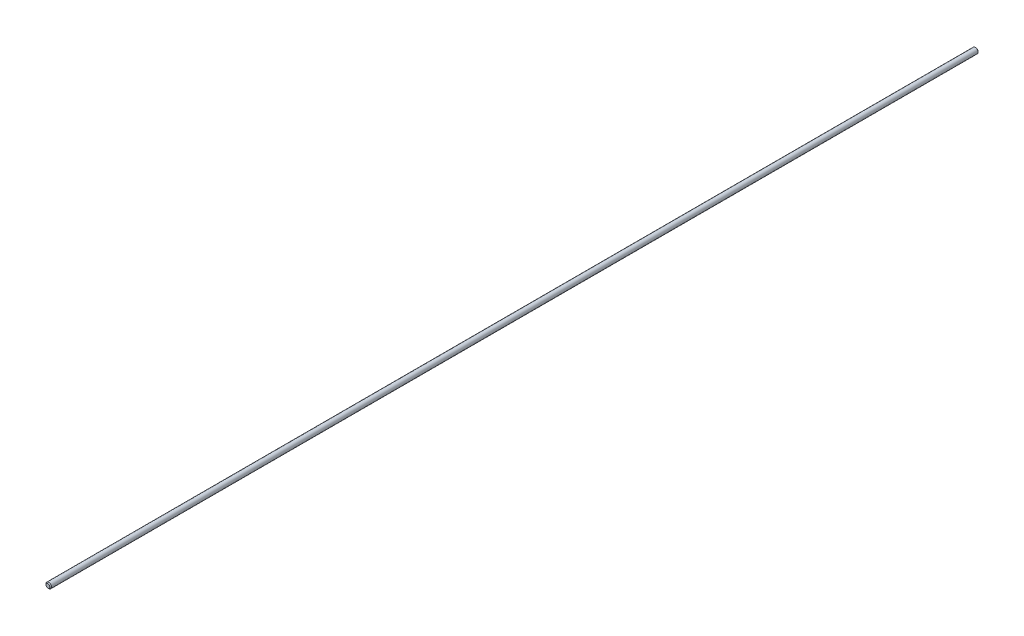
from build123d import *

# Parameters (mm, degrees)
SKETCH2_W     = 534.6954
SKETCH2_H     = 1.5875
CHAMFER1_SIZE = 0.47625


with BuildPart() as part:
    # Sketch2 → Revolve1 (revolve)
    with BuildSketch(Plane(origin=(0, 0, 0), x_dir=(0, 0, -1), z_dir=(1, 0, 0))):
        with Locations((0, 0.79375)):
            Rectangle(SKETCH2_W, SKETCH2_H)
    revolve(axis=Axis((0, 0, 267.3477), (0, 0, -1)))

    # Chamfer1
    chamfer1_edges = [part.edges().sort_by_distance(p)[0] for p in [
        (0, -1.5875, -267.3477),
        (0, -1.5875, 267.3477),
    ]]
    chamfer(chamfer1_edges, length=CHAMFER1_SIZE)


solid = part.part
